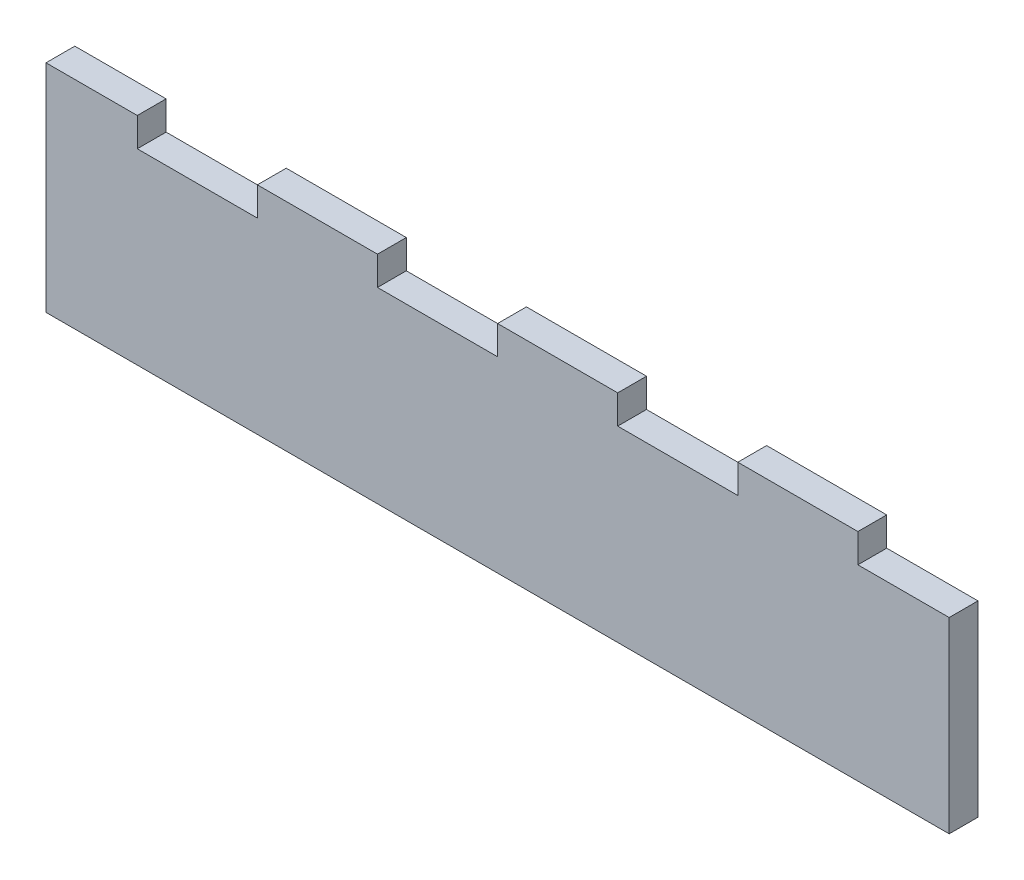
from build123d import *

# Parameters (mm, degrees)
RESSALTO_EXTRUS_O1_DEPTH = 6


with BuildPart() as part:
    # Esboço1 → Ressalto-extrusão1 (new body)
    with BuildSketch(Plane.XY):
        Polygon((169, 39), (188, 39), (188, 0), (0, 0), (0, 39), (0, 45), (19, 45), (19, 39), (44, 39), (44, 45), (69, 45), (69, 39), (94, 39), (94, 45), (119, 45), (119, 39), (144, 39), (144, 45), (169, 45), align=None)
    extrude(amount=RESSALTO_EXTRUS_O1_DEPTH)


solid = part.part
